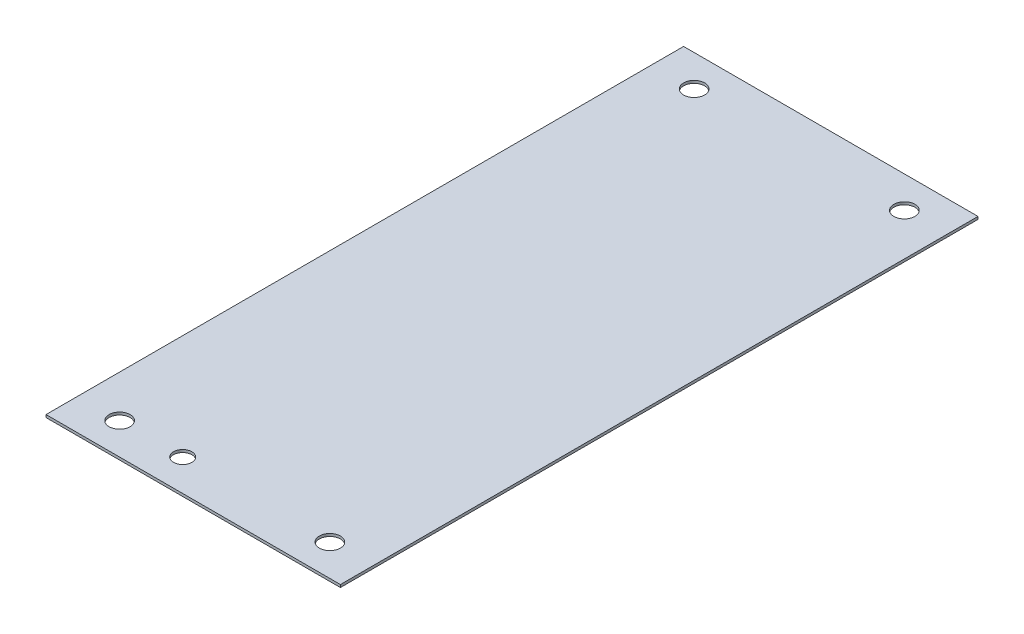
from build123d import *

# Parameters (mm, degrees)
SKETCH1_W                  = 355.6
SKETCH1_H                  = 770.128
BOSS_EXTRUDE1_DEPTH        = 3.175
F_1_1_DIAMETER_HOLE1_D     = 25.4
F_1_1_DIAMETER_HOLE1_DEPTH = 20.574
F_1_1_DIAMETER_HOLE1_TIP   = 7.630929862
SKETCH4_R                  = 11.1125
CUT_EXTRUDE1_DEPTH         = 4.175


with BuildPart() as part:
    # Sketch1 → Boss-Extrude1 (new body)
    with BuildSketch(Plane(origin=(0, 0, 0), x_dir=(1, 0, 0), z_dir=(0, 1, 0))):
        with Locations((177.8, 385.064)):
            Rectangle(SKETCH1_W, SKETCH1_H)
    extrude(amount=BOSS_EXTRUDE1_DEPTH)

    # 1 (1) Diameter Hole1
    with Locations(Plane(origin=(0, 3.175, 0), x_dir=(-1, 0, 0), z_dir=(0, 1, 0))):
        with Locations((-50.8, -38.1), (-50.8, -732.028), (-304.8, -732.028), (-304.8, -38.1)):
            Hole(F_1_1_DIAMETER_HOLE1_D / 2, depth=F_1_1_DIAMETER_HOLE1_DEPTH)
            with Locations((0, 0, -(F_1_1_DIAMETER_HOLE1_DEPTH + F_1_1_DIAMETER_HOLE1_TIP / 2))):  # 118° drill point
                Cone(0, F_1_1_DIAMETER_HOLE1_D / 2, F_1_1_DIAMETER_HOLE1_TIP, mode=Mode.SUBTRACT)

    # Sketch4 → Cut-Extrude1 (cut, through all)
    with BuildSketch(Plane(origin=(0, 3.175, 0), x_dir=(1, 0, 0), z_dir=(0, 1, 0))):
        with Locations((127, 38.1)):
            Circle(SKETCH4_R)
    extrude(amount=-CUT_EXTRUDE1_DEPTH, mode=Mode.SUBTRACT)


solid = part.part
